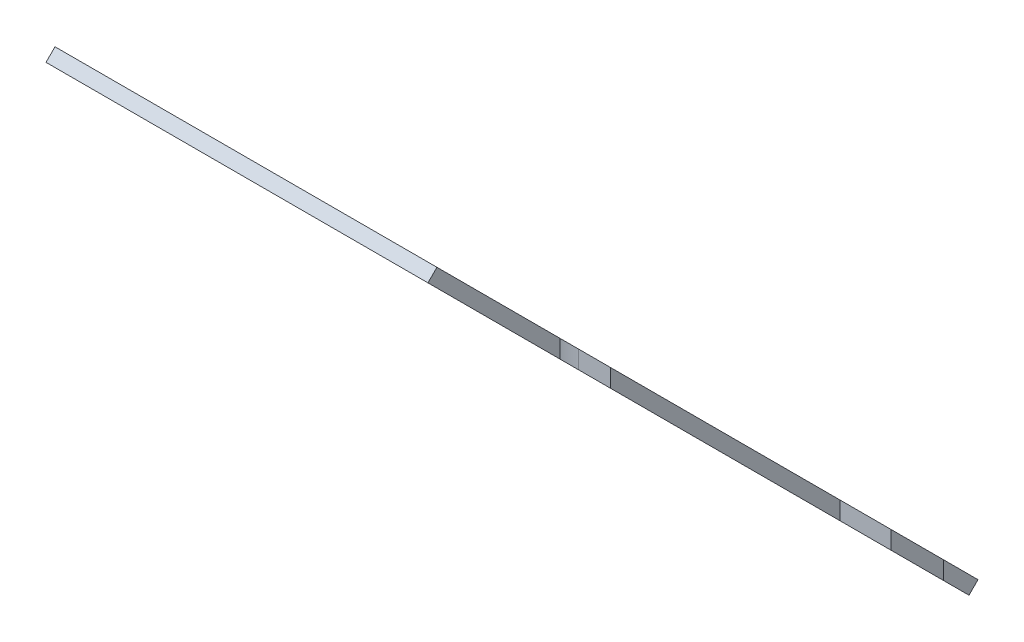
from build123d import *

# Parameters (mm, degrees)
BOSS_EXTRUDE1_START = -22799.561142
BOSS_EXTRUDE1_DEPTH = 600
CUT_EXTRUDE1_START  = 2893.690104
CUT_EXTRUDE1_DEPTH  = 548.284271
BOSS_EXTRUDE2_DEPTH = 498
CUT_EXTRUDE2_DEPTH  = 694.125788176


with BuildPart() as part:
    # Sketch3 → Boss-Extrude1 (new body)
    with BuildSketch(Plane(origin=(0, 0, 0), x_dir=(0, 0, -1), z_dir=(1, 0, 0)).offset(BOSS_EXTRUDE1_START)):
        Polygon((-40199.900196056, 2810.990103756), (-41009.724036196, 3620.813943896), (-40995.581900573, 3634.95607952), (-40199.900196056, 2839.274375003), align=None)
    extrude(amount=-BOSS_EXTRUDE1_DEPTH)

    # Sketch4 → Cut-Extrude1 (cut)
    with BuildSketch(Plane(origin=(0, 0, 0), x_dir=(1, 0, 0), z_dir=(0, 1, 0)).offset(CUT_EXTRUDE1_START)):
        with BuildLine():
            Line((-22799.561141737, -40362.600196057), (-23030.561141738, -40362.600196057))
            ThreePointArc((-23030.561141738, -40362.600196057), (-23070.561141738, -40322.600196057), (-23030.561141738, -40282.600196057))
            Line((-23030.561141738, -40282.600196057), (-22799.561141737, -40282.600196057))
            Line((-22799.561141737, -40282.600196057), (-22799.561141737, -40362.600196057))
        make_face()
        with BuildLine():
            Line((-22799.561141737, -40802.600196057), (-22850.561141738, -40802.600196057))
            ThreePointArc((-22850.561141738, -40802.600196057), (-22890.561141738, -40762.600196057), (-22850.561141738, -40722.600196057))
            Line((-22850.561141738, -40722.600196057), (-22799.561141737, -40722.600196057))
            Line((-22799.561141737, -40722.600196057), (-22799.561141737, -40802.600196057))
        make_face()
    extrude(amount=CUT_EXTRUDE1_DEPTH, mode=Mode.SUBTRACT)

    # Sketch5 → Boss-Extrude2 (add)
    with BuildSketch(Plane.ZY.offset(23399.561141738)):
        Polygon((40057.780417375, 2668.870325074), (40199.900196056, 2810.990103756), (40199.900196056, 2839.274375003), (40043.638281751, 2683.012460698), align=None)
    extrude(amount=-BOSS_EXTRUDE2_DEPTH)

    # Sketch6 → Cut-Extrude2 (cut, through all)
    with BuildSketch(Plane(origin=(0, -18680.312910526, 18680.312910527), x_dir=(1, 0, 0), z_dir=(0, 0.707106781, -0.707106781))):
        with BuildLine():
            Line((-23349.561141737, -30397.304477375), (-23159.561141737, -30397.304477375))
            ThreePointArc((-23159.561141737, -30397.304477375), (-23149.561141737, -30387.304477375), (-23159.561141737, -30377.304477375))
            Line((-23159.561141737, -30377.304477375), (-23359.561141737, -30377.304477375))
            ThreePointArc((-23359.561141737, -30377.304477375), (-23366.632209549, -30380.233409563), (-23369.561141737, -30387.304477375))
            Line((-23369.561141737, -30387.304477375), (-23369.561141737, -31189.304477375))
            ThreePointArc((-23369.561141737, -31189.304477375), (-23366.632209549, -31196.375545187), (-23359.561141737, -31199.304477375))
            Line((-23359.561141737, -31199.304477375), (-22990.438858263, -31199.304477375))
            ThreePointArc((-22990.438858263, -31199.304477375), (-22980.438858263, -31189.304477375), (-22990.438858263, -31179.304477375))
            Line((-22990.438858263, -31179.304477375), (-23349.561141737, -31179.304477375))
            Line((-23349.561141737, -31179.304477375), (-23349.561141737, -31019.304477375))
            Line((-23349.561141737, -31019.304477375), (-22990.438858263, -31019.304477375))
            ThreePointArc((-22990.438858263, -31019.304477375), (-22980.438858263, -31009.304477375), (-22990.438858263, -30999.304477375))
            Line((-22990.438858263, -30999.304477375), (-23349.561141737, -30999.304477375))
            Line((-23349.561141737, -30999.304477375), (-23349.561141737, -30577.304477375))
            Line((-23349.561141737, -30577.304477375), (-23159.561141737, -30577.304477375))
            ThreePointArc((-23159.561141737, -30577.304477375), (-23149.561141737, -30567.304477375), (-23159.561141737, -30557.304477375))
            Line((-23159.561141737, -30557.304477375), (-23349.561141737, -30557.304477375))
            Line((-23349.561141737, -30557.304477375), (-23349.561141737, -30397.304477375))
        make_face()
    extrude(amount=-CUT_EXTRUDE2_DEPTH, mode=Mode.SUBTRACT)


solid = part.part
